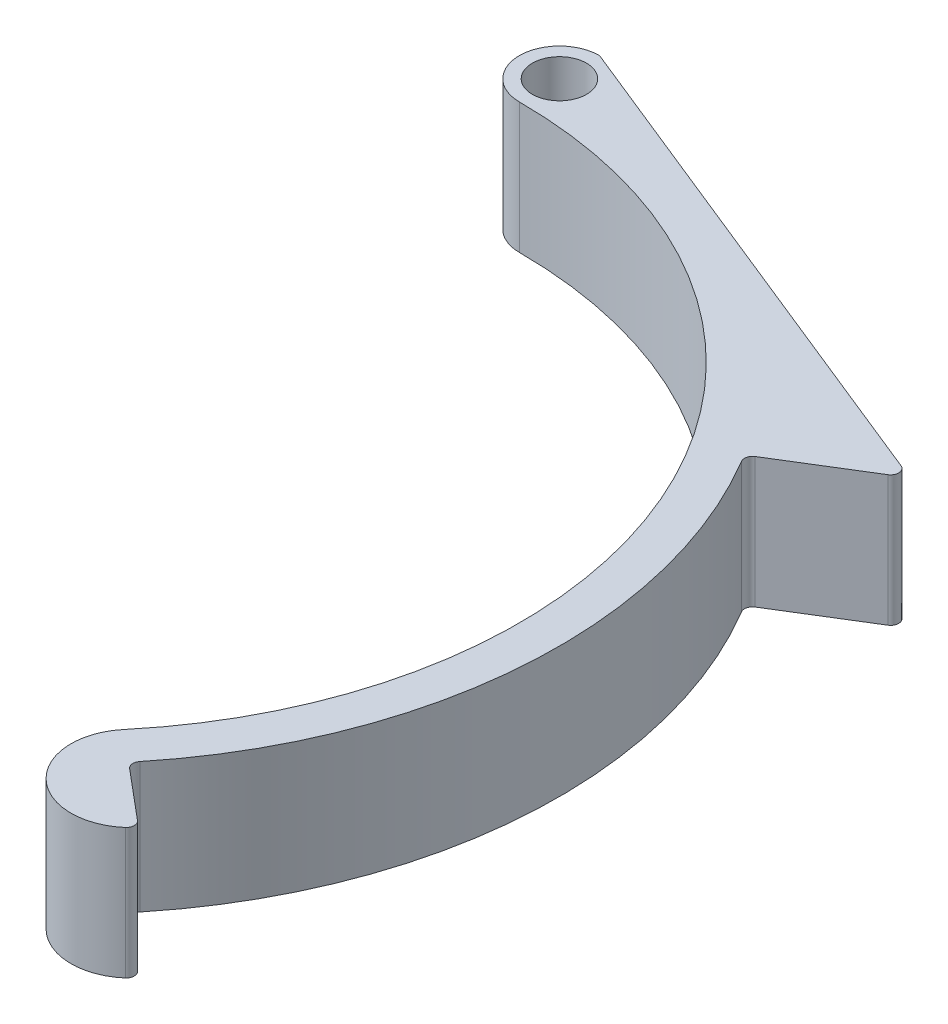
from build123d import *

# Parameters (mm, degrees)
BOSS_EXTRUDE1_DEPTH = 13
FILLET1_R           = 0.8


with BuildPart() as part:
    # Sketch1 → Boss-Extrude1 (new body)
    with BuildSketch(Plane(origin=(0, 0, 0), x_dir=(1, 0, 0), z_dir=(0, 1, 0))):
        with BuildLine():
            Line((0, 51.7), (0, 53))
            ThreePointArc((0, 53), (-4, 49), (0, 45))
            ThreePointArc((0, 45), (40.783850417, 19.017821778), (34.47199994, -28.925442436))
            ThreePointArc((34.47199994, -28.925442436), (35.211540941, -37.378434753), (43.664533258, -36.638893752))
            Line((43.664533258, -36.638893752), (37.536177713, -31.496592875))
            ThreePointArc((37.536177713, -31.496592875), (48.870327604, -3.562454189), (41.707047143, 25.720074234))
            ThreePointArc((41.707047143, 25.720074234), (25.051905135, 42.111780407), (2.698975076, 48.925612245))
            ThreePointArc((2.698975076, 48.925612245), (-1.935309657, 47.117295421), (0, 51.7))
        make_face()
        with BuildLine():
            Line((51.921017872, 32.018867925), (0, 53))
            Line((0, 53), (0, 51.7))
            ThreePointArc((0, 51.7), (1.909188309, 50.909188309), (2.7, 49))
            ThreePointArc((2.7, 49), (2.699743757, 48.962802592), (2.698975076, 48.925612245))
            ThreePointArc((2.698975076, 48.925612245), (25.051905135, 42.111780407), (41.707047143, 25.720074234))
            Line((41.707047143, 25.720074234), (51.921017872, 32.018867925))
        make_face()
    extrude(amount=BOSS_EXTRUDE1_DEPTH)

    # Fillet1
    fillet1_edges = [part.edges().sort_by_distance(p)[0] for p in [
        (0, 6.5, -53),
        (51.921017872, 6.5, -32.018867925),
        (41.707047143, 6.5, -25.720074234),
        (37.536177713, 6.5, 31.496592875),
        (43.664533258, 6.5, 36.638893752),
    ]]
    fillet(fillet1_edges, radius=FILLET1_R)


solid = part.part
